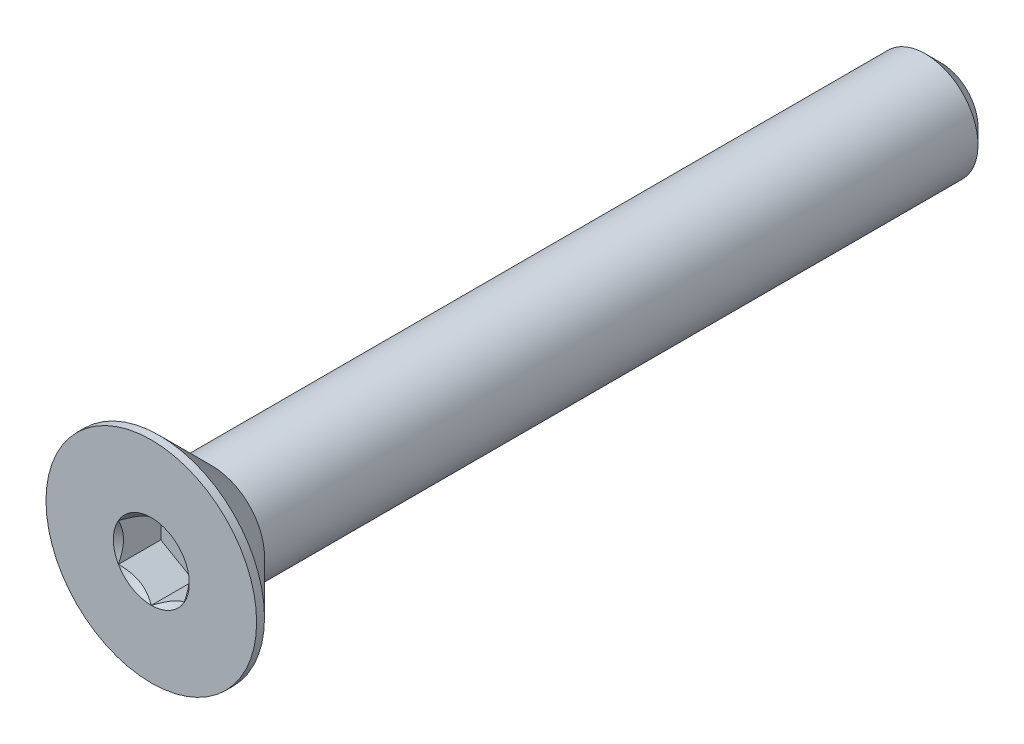
from build123d import *

# Parameters (mm, degrees)
SKETCH3_W          = 30
SKETCH3_H          = 2
CHAMFER1_SIZE      = 0.6
CUT_EXTRUDE1_DEPTH = 1.61
SKETCH9_R          = 1.443375673
CUT_EXTRUDE2_DEPTH = 1.61
CUT_EXTRUDE2_DRAFT = -45


with BuildPart() as part:
    # Sketch3 → Revolve1 (revolve)
    with BuildSketch(Plane(origin=(0, 0, 0), x_dir=(0, 0, -1), z_dir=(1, 0, 0))):
        with Locations((0, 1)):
            Rectangle(SKETCH3_W, SKETCH3_H)
    revolve(axis=Axis((0, 0, -15), (0, 0, 1)))

    # Chamfer1
    chamfer1_edges = [part.edges().sort_by_distance(p)[0] for p in [
        (0, -2, -15),
    ]]
    chamfer(chamfer1_edges, length=CHAMFER1_SIZE)

    # Sketch6 → Revolve2 (revolve)
    with BuildSketch(Plane(origin=(0, 0, 0), x_dir=(0, 0, -1), z_dir=(1, 0, 0))):
        Polygon((-15, 4), (-14.7, 4), (-12.7, 2), (-12.7, 0), (-15, 0), align=None)
    revolve(axis=Axis((0, 0, -15), (0, 0, 1)))

    # Sketch8 → Cut-Extrude1 (cut)
    with BuildSketch(Plane.XY.offset(15)):
        Polygon((0, 1.443375673), (-1.25, 0.721687836), (-1.25, -0.721687836), (0, -1.443375673), (1.25, -0.721687836), (1.25, 0.721687836), align=None)
    extrude(amount=-CUT_EXTRUDE1_DEPTH, mode=Mode.SUBTRACT)


with BuildPart() as cut_extrude2_tool:
    # Sketch9 → Cut-Extrude2 (with draft: the straight prism first)
    with BuildSketch(Plane.XY.offset(15)):
        Circle(SKETCH9_R)
    extrude(amount=-CUT_EXTRUDE2_DEPTH)
    # Cut-Extrude2: the draft: its side faces are tilted about the plane it starts from
    cut_extrude2_sides = [cut_extrude2_tool.faces().sort_by_distance(p)[0] for p in [
        (-1.443375673, 0, 14.195),
    ]]
    draft(cut_extrude2_sides, Plane.XY.offset(15), CUT_EXTRUDE2_DRAFT)


with BuildPart() as part_1:
    add(part.part)

    # Cut-Extrude2: cut by cut_extrude2_tool
    add(cut_extrude2_tool.part, mode=Mode.SUBTRACT)


solid = part_1.part
